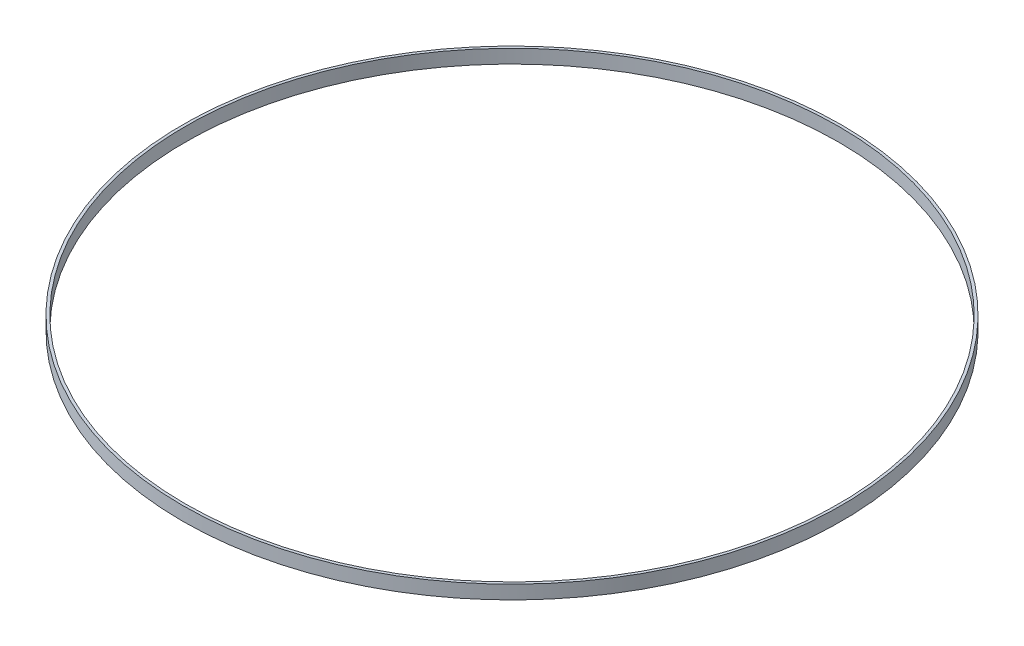
from build123d import *

# Parameters (mm, degrees)
SKETCH1_R           = 30.5943
SKETCH1_R_2         = 30.3403
BOSS_EXTRUDE1_DEPTH = 1.27


with BuildPart() as part:
    # Sketch1 → Boss-Extrude1 (new body)
    with BuildSketch(Plane(origin=(0, 0, 0), x_dir=(1, 0, 0), z_dir=(0, 1, 0))):
        Circle(SKETCH1_R)
        Circle(SKETCH1_R_2, mode=Mode.SUBTRACT)
    extrude(amount=BOSS_EXTRUDE1_DEPTH)


solid = part.part
